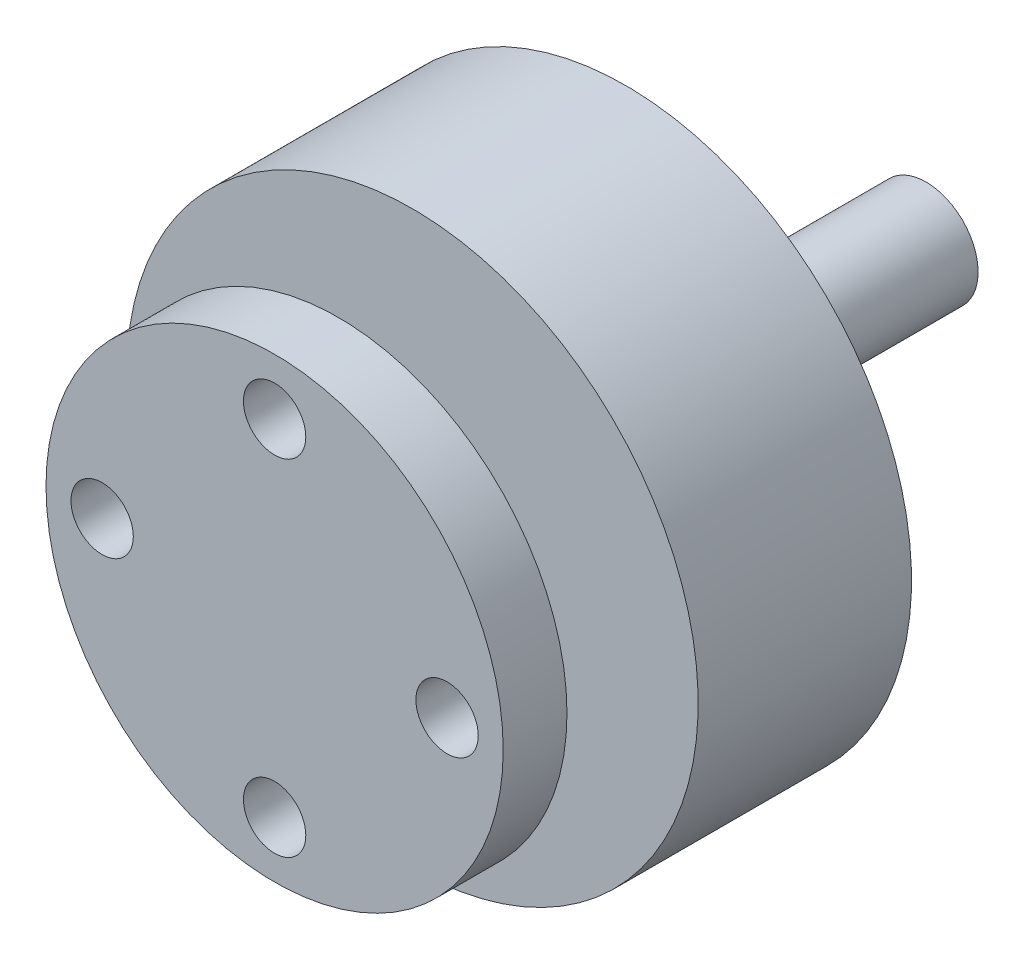
from build123d import *

# Parameters (mm, degrees)
SKETCH2_R          = 1.5
CUT_EXTRUDE1_DEPTH = 5


with BuildPart() as part:
    # Sketch1 → Revolve1 (revolve)
    with BuildSketch(Plane(origin=(0, 0, 0), x_dir=(1, 0, 0), z_dir=(0, 1, 0))):
        Polygon((0, 0), (11, 0), (11, 3.06822983), (3.73856208, 3.06822983), (3.73856208, 6.631290685), (13.75, 6.631290685), (13.75, 16.896299341), (7.819804578, 19.35), (2.5, 19.35), (2.5, 31.35), (0, 31.35), align=None)
    revolve(axis=Axis((0, 0, -31.35), (0, 0, 1)))

    # Sketch2 → Cut-Extrude1 (cut)
    with BuildSketch(Plane.XY):
        with Locations((8.298889382, 0)):
            Circle(SKETCH2_R)
        with Locations((0, -8.298889382)):
            Circle(SKETCH2_R)
        with Locations((-8.298889382, 0)):
            Circle(SKETCH2_R)
        with Locations((0, 8.298889382)):
            Circle(SKETCH2_R)
    extrude(amount=-CUT_EXTRUDE1_DEPTH, mode=Mode.SUBTRACT)


solid = part.part
